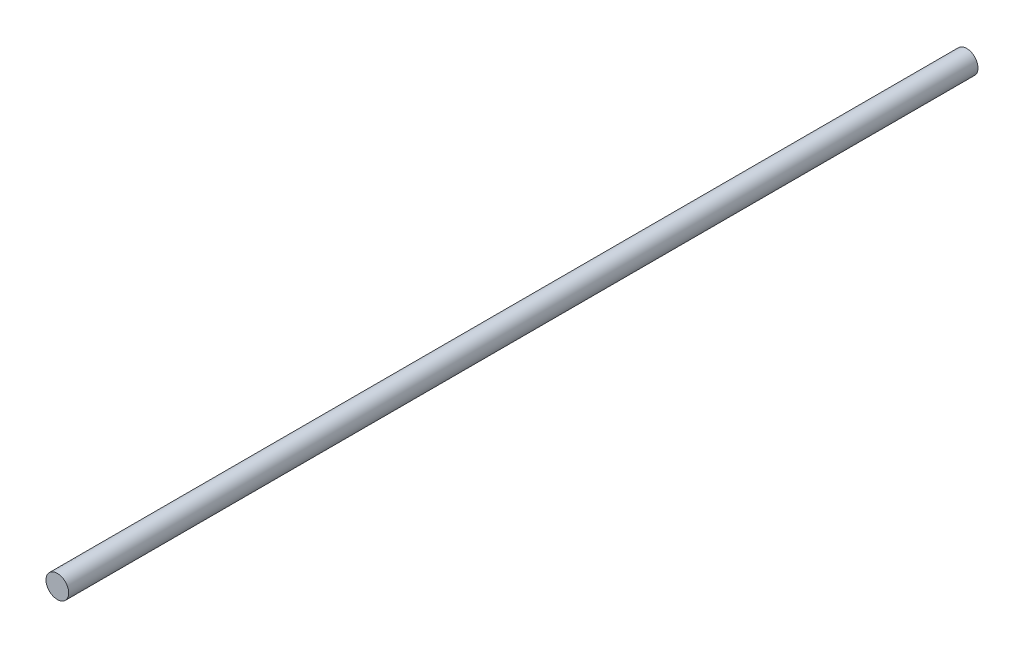
from build123d import *

# Parameters (mm, degrees)
SKETCH1_R           = 6.35
BOSS_EXTRUDE1_DEPTH = 508


with BuildPart() as part:
    # Sketch1 → Boss-Extrude1 (new body)
    with BuildSketch(Plane.XY):
        Circle(SKETCH1_R)
    extrude(amount=BOSS_EXTRUDE1_DEPTH)


solid = part.part
